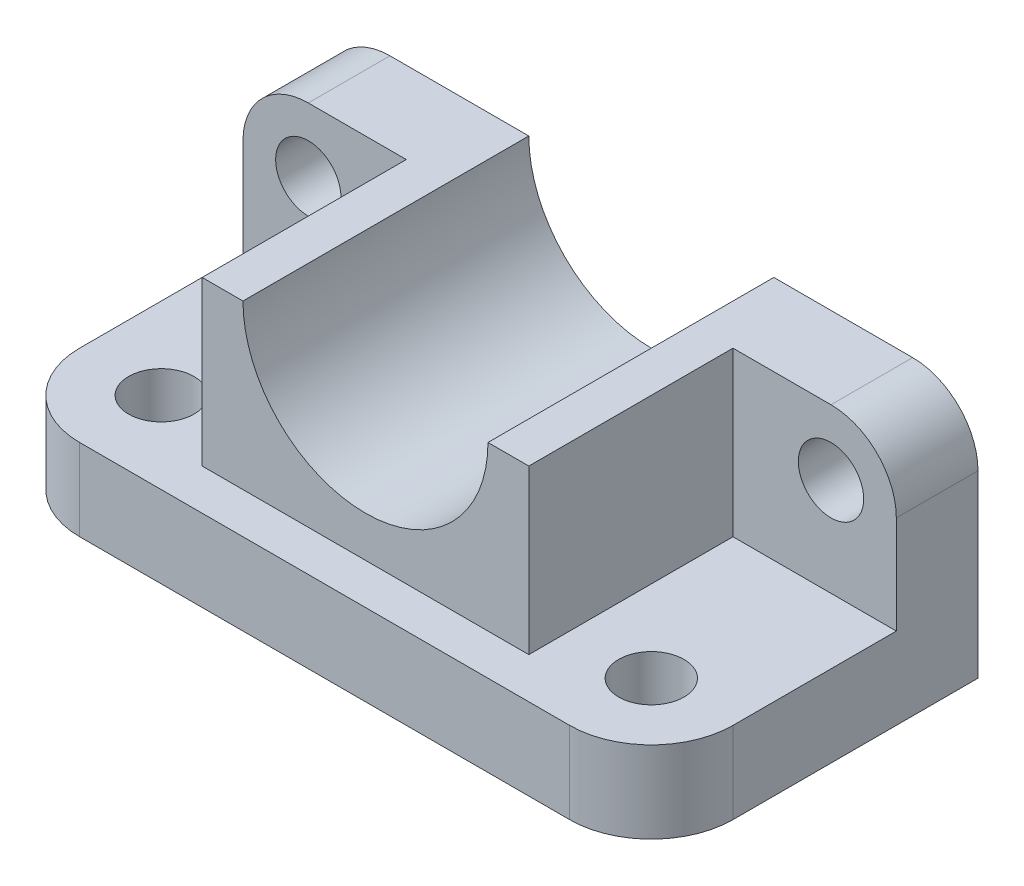
from build123d import *

# Parameters (mm, degrees)
SKETCH_1_R          = 4
EXTRUDE_1_DEPTH     = 30
CUT_EXTRUDE_1_DEPTH = 20
FILLET_1_R          = 8
SKETCH_3_R          = 4
CUT_EXTRUDE_2_DEPTH = 41


with BuildPart() as part:
    # 스케치1 → 보스-돌출1 (new body)
    with BuildSketch(Plane(origin=(0, 0, 0), x_dir=(1, 0, 0), z_dir=(0, 1, 0))):
        with BuildLine():
            Line((-30, -20), (30, -20))
            ThreePointArc((30, -20), (37.071067812, -17.071067812), (40, -10))
            Line((40, -10), (40, 20))
            Line((40, 20), (-40, 20))
            Line((-40, 20), (-40, -10))
            ThreePointArc((-40, -10), (-37.071067812, -17.071067812), (-30, -20))
        make_face()
        with Locations(Location((-30, -10, 0), (0, 0, 270))):  # turned: the seam where the file's is
            Circle(SKETCH_1_R, mode=Mode.SUBTRACT)
        with Locations(Location((30, -10, 0), (0, 0, 270))):  # turned: the seam where the file's is
            Circle(SKETCH_1_R, mode=Mode.SUBTRACT)
    extrude(amount=EXTRUDE_1_DEPTH)

    # 스케치2 → 컷-돌출1 (cut)
    with BuildSketch(Plane(origin=(0, 30, 0), x_dir=(1, 0, 0), z_dir=(0, 1, 0))):
        with BuildLine():
            Line((40, -10), (40, 10))
            Line((40, 10), (20, 10))
            Line((20, 10), (20, -15))
            Line((20, -15), (-20, -15))
            Line((-20, -15), (-20, 10))
            Line((-20, 10), (-40, 10))
            Line((-40, 10), (-40, -10))
            ThreePointArc((-40, -10), (-37.071067812, -17.071067812), (-30, -20))
            Line((-30, -20), (30, -20))
            ThreePointArc((30, -20), (37.071067812, -17.071067812), (40, -10))
        make_face()
    extrude(amount=-CUT_EXTRUDE_1_DEPTH, mode=Mode.SUBTRACT)

    # 필렛1
    fillet_1_edges = [part.edges().sort_by_distance(p)[0] for p in [
        (-40, 30, -15),
        (40, 30, -15),
    ]]
    fillet(fillet_1_edges, radius=FILLET_1_R)

    # 스케치3 → 컷-돌출2 (cut, through all)
    with BuildSketch(Plane.XY.offset(20)):
        with Locations((-32, 22)):
            Circle(SKETCH_3_R)
        with Locations((32, 22)):
            Circle(SKETCH_3_R)
        with BuildLine():
            Line((15, 30), (-15, 30))
            ThreePointArc((-15, 30), (0, 15), (15, 30))
        make_face()
    extrude(amount=-CUT_EXTRUDE_2_DEPTH, mode=Mode.SUBTRACT)


solid = part.part
